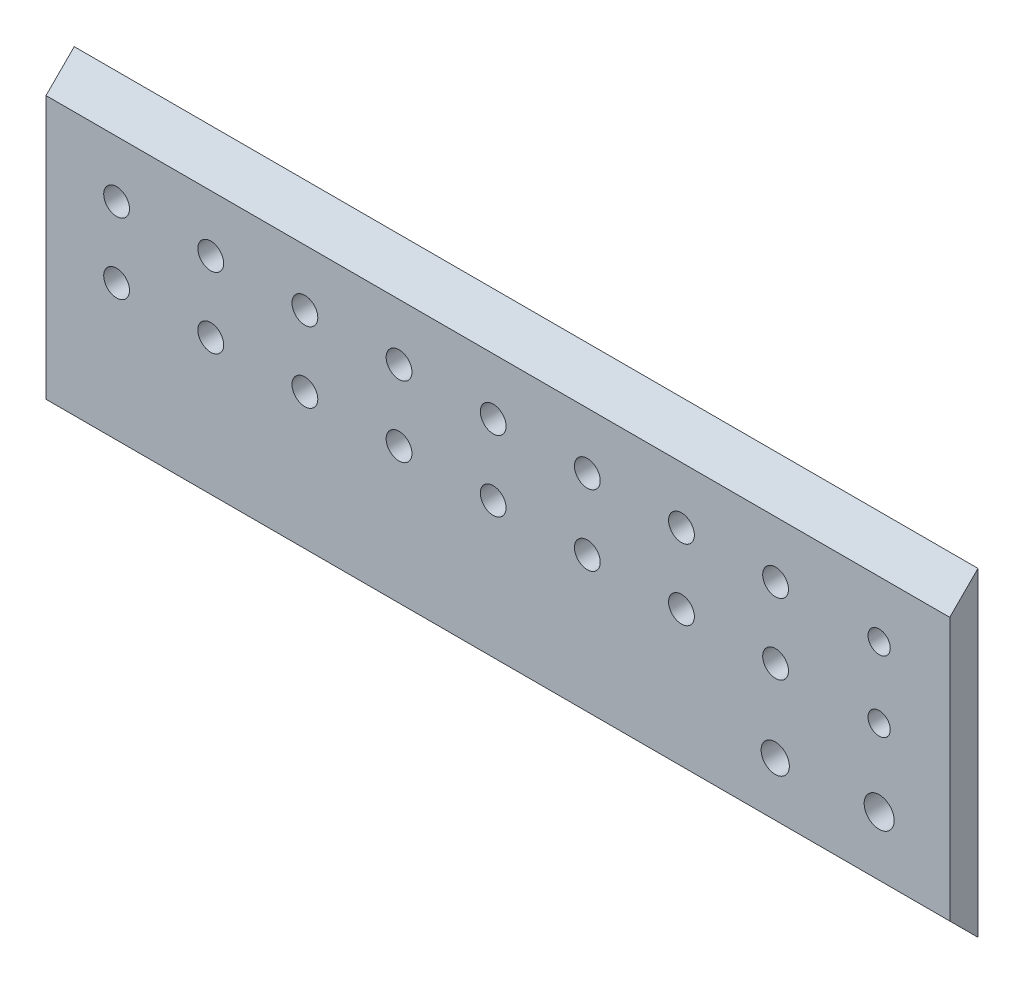
from build123d import *

# Parameters (mm, degrees)
SKETCH2_W                 = 203.2
SKETCH2_H                 = 71.842048969
BOSS_EXTRUDE1_DEPTH       = 6.35
CUT_EXTRUDE1_DEPTH        = 203.2
CUT_EXTRUDE3_DEPTH        = 203.2
SKETCH7_R                 = 2.9
CUT_EXTRUDE4_DEPTH        = 6.35
LPATTERN1_COUNT           = 8
LPATTERN1_PITCH           = 21.166666667
LPATTERN2_COUNT           = 2
LPATTERN2_PITCH           = 15.875
LPATTERN2_COPY_1_SKETCH_R = 2.9
LPATTERN2_COPY_1_DEPTH    = 6.35
LPATTERN2_COPY_2_SKETCH_R = 2.9
LPATTERN2_COPY_2_DEPTH    = 6.35
LPATTERN2_COPY_3_SKETCH_R = 2.9
LPATTERN2_COPY_3_DEPTH    = 6.35
LPATTERN2_COPY_4_SKETCH_R = 2.9
LPATTERN2_COPY_4_DEPTH    = 6.35
LPATTERN2_COPY_5_SKETCH_R = 2.9
LPATTERN2_COPY_5_DEPTH    = 6.35
LPATTERN2_COPY_6_SKETCH_R = 2.9
LPATTERN2_COPY_6_DEPTH    = 6.35
LPATTERN2_COPY_7_SKETCH_R = 2.9
LPATTERN2_COPY_7_DEPTH    = 6.35
SKETCH8_R                 = 2.5
CUT_EXTRUDE5_DEPTH        = 6.35
LPATTERN3_COUNT           = 2
LPATTERN3_PITCH           = 15.875
SKETCH9_R                 = 3.375
CUT_EXTRUDE6_DEPTH        = 6.35
SKETCH12_R                = 3.175
CUT_EXTRUDE7_DEPTH        = 6.35


with BuildPart() as part:
    # Sketch2 → Boss-Extrude1 (new body)
    with BuildSketch(Plane.XY):
        with Locations((101.6, 35.921024485)):
            Rectangle(SKETCH2_W, SKETCH2_H)
    extrude(amount=BOSS_EXTRUDE1_DEPTH)

    # Sketch3 → Cut-Extrude1 (cut)
    with BuildSketch(Plane.ZY):
        Polygon((0, 0), (6.35, 0), (6.35, 6.35), align=None)
    extrude(amount=-CUT_EXTRUDE1_DEPTH, mode=Mode.SUBTRACT)

    # Sketch5 → Cut-Extrude3 (cut)
    with BuildSketch(Plane.ZY):
        Polygon((6.35, 71.842048969), (6.35, 65.492048969), (0, 71.842048969), align=None)
    extrude(amount=-CUT_EXTRUDE3_DEPTH, mode=Mode.SUBTRACT)

    # Sketch7 → Cut-Extrude4 (cut)
    with BuildSketch(Plane.XY.offset(6.35)):
        with Locations((15.875, 52.792048969)):
            Circle(SKETCH7_R)
    cut_extrude4 = extrude(amount=-CUT_EXTRUDE4_DEPTH, mode=Mode.SUBTRACT)

    # LPattern1: Cut-Extrude4 ×8
    with Locations(*[(i * LPATTERN1_PITCH, 0, 0) for i in range(1, LPATTERN1_COUNT)]):
        add(cut_extrude4, mode=Mode.SUBTRACT)

    # LPattern2: Cut-Extrude4 ×2
    with Locations(*[(0, -i * LPATTERN2_PITCH, 0) for i in range(1, LPATTERN2_COUNT)]):
        add(cut_extrude4, mode=Mode.SUBTRACT)

    # LPattern2 copy 1 sketch → LPattern2 copy 1 (cut)
    with BuildSketch(Plane(origin=(21.166666667, -15.875, 6.35), x_dir=(1, 0, 0), z_dir=(0, 0, 1))):
        with Locations((15.875, 52.792048969)):
            Circle(LPATTERN2_COPY_1_SKETCH_R)
    extrude(amount=-LPATTERN2_COPY_1_DEPTH, mode=Mode.SUBTRACT)

    # LPattern2 copy 2 sketch → LPattern2 copy 2 (cut)
    with BuildSketch(Plane(origin=(42.333333333, -15.875, 6.35), x_dir=(1, 0, 0), z_dir=(0, 0, 1))):
        with Locations((15.875, 52.792048969)):
            Circle(LPATTERN2_COPY_2_SKETCH_R)
    extrude(amount=-LPATTERN2_COPY_2_DEPTH, mode=Mode.SUBTRACT)

    # LPattern2 copy 3 sketch → LPattern2 copy 3 (cut)
    with BuildSketch(Plane(origin=(63.5, -15.875, 6.35), x_dir=(1, 0, 0), z_dir=(0, 0, 1))):
        with Locations((15.875, 52.792048969)):
            Circle(LPATTERN2_COPY_3_SKETCH_R)
    extrude(amount=-LPATTERN2_COPY_3_DEPTH, mode=Mode.SUBTRACT)

    # LPattern2 copy 4 sketch → LPattern2 copy 4 (cut)
    with BuildSketch(Plane(origin=(84.666666667, -15.875, 6.35), x_dir=(1, 0, 0), z_dir=(0, 0, 1))):
        with Locations((15.875, 52.792048969)):
            Circle(LPATTERN2_COPY_4_SKETCH_R)
    extrude(amount=-LPATTERN2_COPY_4_DEPTH, mode=Mode.SUBTRACT)

    # LPattern2 copy 5 sketch → LPattern2 copy 5 (cut)
    with BuildSketch(Plane(origin=(105.833333333, -15.875, 6.35), x_dir=(1, 0, 0), z_dir=(0, 0, 1))):
        with Locations((15.875, 52.792048969)):
            Circle(LPATTERN2_COPY_5_SKETCH_R)
    extrude(amount=-LPATTERN2_COPY_5_DEPTH, mode=Mode.SUBTRACT)

    # LPattern2 copy 6 sketch → LPattern2 copy 6 (cut)
    with BuildSketch(Plane(origin=(127, -15.875, 6.35), x_dir=(1, 0, 0), z_dir=(0, 0, 1))):
        with Locations((15.875, 52.792048969)):
            Circle(LPATTERN2_COPY_6_SKETCH_R)
    extrude(amount=-LPATTERN2_COPY_6_DEPTH, mode=Mode.SUBTRACT)

    # LPattern2 copy 7 sketch → LPattern2 copy 7 (cut)
    with BuildSketch(Plane(origin=(148.166666667, -15.875, 6.35), x_dir=(1, 0, 0), z_dir=(0, 0, 1))):
        with Locations((15.875, 52.792048969)):
            Circle(LPATTERN2_COPY_7_SKETCH_R)
    extrude(amount=-LPATTERN2_COPY_7_DEPTH, mode=Mode.SUBTRACT)

    # Sketch8 → Cut-Extrude5 (cut)
    with BuildSketch(Plane.XY.offset(6.35)):
        with Locations((187.325, 52.792048969)):
            Circle(SKETCH8_R)
    cut_extrude5 = extrude(amount=-CUT_EXTRUDE5_DEPTH, mode=Mode.SUBTRACT)

    # LPattern3: Cut-Extrude5 ×2
    with Locations(*[(0, -i * LPATTERN3_PITCH, 0) for i in range(1, LPATTERN3_COUNT)]):
        add(cut_extrude5, mode=Mode.SUBTRACT)

    # Sketch9 → Cut-Extrude6 (cut)
    with BuildSketch(Plane.XY.offset(6.35)):
        with Locations((187.325, 19.651113798)):
            Circle(SKETCH9_R)
    extrude(amount=-CUT_EXTRUDE6_DEPTH, mode=Mode.SUBTRACT)

    # Sketch12 → Cut-Extrude7 (cut)
    with BuildSketch(Plane.XY.offset(6.35)):
        with Locations((163.957, 18.464225693)):
            Circle(SKETCH12_R)
    extrude(amount=-CUT_EXTRUDE7_DEPTH, mode=Mode.SUBTRACT)


solid = part.part
